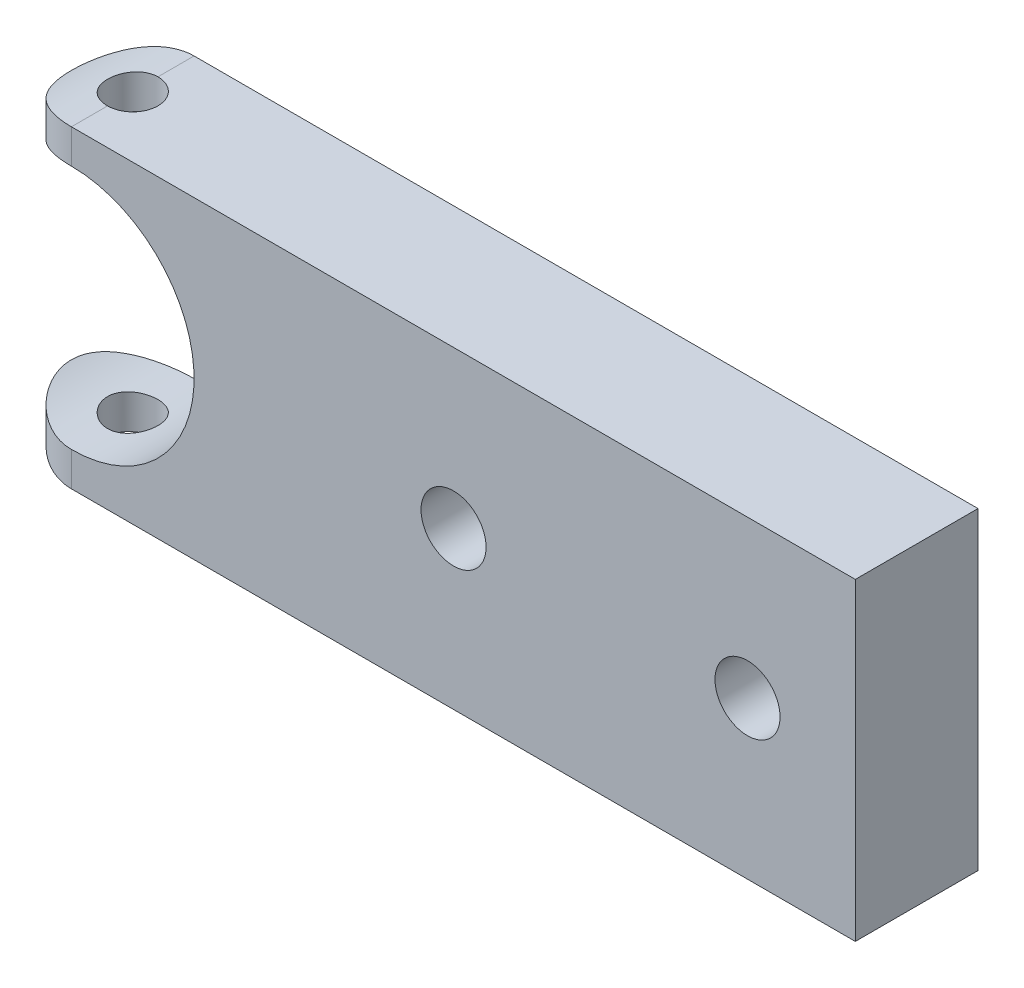
from build123d import *

# Parameters (mm, degrees)
BOSS_EXTRUDE1_DEPTH                       = 15.9004
SKETCH2_R                                 = 15.9004
CUT_EXTRUDE1_DEPTH                        = 2.54
CUT_EXTRUDE1_DEPTH_BACK                   = 18.796
CBORE_FOR_5_16_HEX_HEAD_BOLT1_D           = 8.4328
CBORE_FOR_5_16_HEX_HEAD_BOLT1_CBORE_D     = 20.6375
CBORE_FOR_5_16_HEX_HEAD_BOLT1_CBORE_DEPTH = 5.969
F_5_16_18_TAPPED_HOLE1_D                  = 6.5278
CUT_EXTRUDE2_DEPTH                        = 40.894


with BuildPart() as part:
    # Sketch1 → Boss-Extrude1 (new body)
    with BuildSketch(Plane.XY):
        with BuildLine():
            Line((50.8, -20.32), (-50.8, -20.32))
            ThreePointArc((-50.8, -20.32), (-71.12, 0), (-50.8, 20.32))
            Line((-50.8, 20.32), (50.8, 20.32))
            Line((50.8, 20.32), (50.8, -20.32))
        make_face()
    extrude(amount=BOSS_EXTRUDE1_DEPTH)

    # Sketch2 → Cut-Extrude1 (cut, two sides)
    with BuildSketch(Plane(origin=(2.48157472, 0, 15.9004), x_dir=(1, 0, 0), z_dir=(0, 0, 1))) as cut_extrude1_sk:
        with Locations((-53.28157472, 0)):
            Circle(SKETCH2_R)
    extrude(amount=CUT_EXTRUDE1_DEPTH, mode=Mode.SUBTRACT)
    extrude(cut_extrude1_sk.sketch, amount=-CUT_EXTRUDE1_DEPTH_BACK, mode=Mode.SUBTRACT)

    # CBORE for 5/16 Hex Head Bolt1 (through all)
    with Locations(Plane(origin=(0, 0, 0), x_dir=(-1, 0, 0), z_dir=(0, 0, -1))):
        with Locations((-36.83, 0), (1.27, 0)):
            CounterBoreHole(CBORE_FOR_5_16_HEX_HEAD_BOLT1_D / 2, CBORE_FOR_5_16_HEX_HEAD_BOLT1_CBORE_D / 2, CBORE_FOR_5_16_HEX_HEAD_BOLT1_CBORE_DEPTH)

    # 5/16-18 Tapped Hole1 (through all)
    with Locations(Plane(origin=(0, -20.32, 0), x_dir=(-1, 0, 0), z_dir=(0, -1, 0))):
        with Locations((50.8, -7.9502)):
            Hole(F_5_16_18_TAPPED_HOLE1_D / 2)

    # Sketch10 → Cut-Extrude2 (cut)
    with BuildSketch(Plane.XZ.offset(20.32)):
        with BuildLine():
            Line((-50.8, 15.9004), (-71.468119006, 15.9004))
            Line((-71.468119006, 15.9004), (-71.468119006, 0))
            Line((-71.468119006, 0), (-50.8, 0))
            ThreePointArc((-50.8, 0), (-58.7502, 7.9502), (-50.8, 15.9004))
        make_face()
    extrude(amount=-CUT_EXTRUDE2_DEPTH, mode=Mode.SUBTRACT)


solid = part.part
